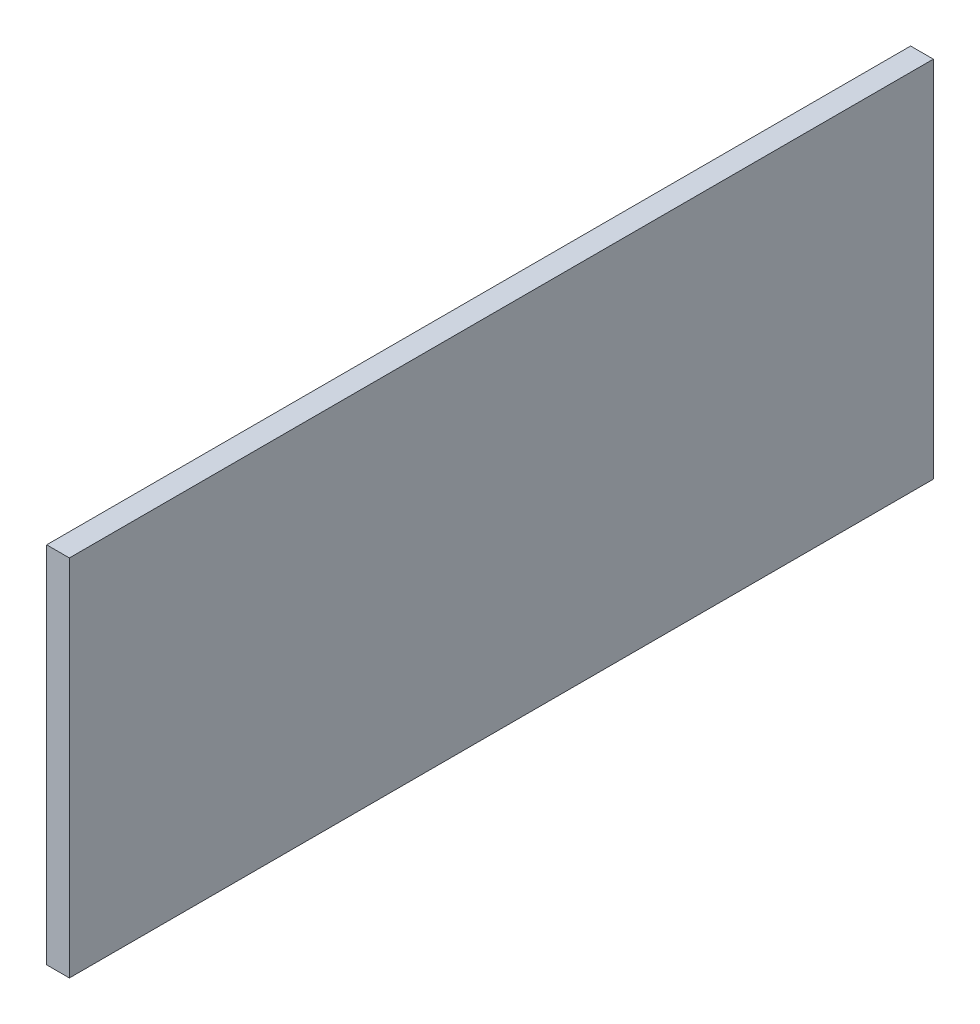
from build123d import *

# Parameters (mm, degrees)
SKETCH1_W           = 203.2
SKETCH1_H           = 120.65
BOSS_EXTRUDE1_DEPTH = 50.8
SKETCH2_W           = 196.85
SKETCH2_H           = 114.3
CUT_EXTRUDE1_DEPTH  = 51.8
SKETCH4_W           = 203.2
SKETCH4_H           = 120.65
SKETCH4_W_2         = 196.85
SKETCH4_H_2         = 114.3
BOSS_EXTRUDE2_DEPTH = 6.35
CUT_EXTRUDE5_DEPTH  = 121.65
CUT_EXTRUDE6_REACH  = 205.2
CUT_EXTRUDE7_REACH  = 205.2
SKETCH13_R          = 12.55395
SKETCH14_W          = 200.025
SKETCH14_H          = 120.65
CUT_EXTRUDE8_DEPTH  = 51.8
BOSS_EXTRUDE3_DEPTH = 3.175


with BuildPart() as part:
    # Sketch1 → Boss-Extrude1 (new body)
    with BuildSketch(Plane(origin=(0, 0, 0), x_dir=(1, 0, 0), z_dir=(0, 1, 0))):
        Rectangle(SKETCH1_W, SKETCH1_H)
    extrude(amount=BOSS_EXTRUDE1_DEPTH)

    # Sketch2 → Cut-Extrude1 (cut, through all)
    with BuildSketch(Plane(origin=(0, 50.8, 0), x_dir=(1, 0, 0), z_dir=(0, 1, 0))):
        Rectangle(SKETCH2_W, SKETCH2_H)
    extrude(amount=-CUT_EXTRUDE1_DEPTH, mode=Mode.SUBTRACT)

    # Sketch4 → Boss-Extrude2 (add)
    with BuildSketch(Plane(origin=(0, 50.8, 0), x_dir=(1, 0, 0), z_dir=(0, 1, 0))):
        Rectangle(SKETCH4_W, SKETCH4_H)
        Rectangle(SKETCH4_W_2, SKETCH4_H_2, mode=Mode.SUBTRACT)
    extrude(amount=-BOSS_EXTRUDE2_DEPTH)

    # Sketch10 → Cut-Extrude5 (cut, through all)
    with BuildSketch(Plane.XY.offset(60.325)):
        with BuildLine():
            ThreePointArc((-65.9511, 22.225), (-81.206975571, 31.167602912), (-81.556705839, 13.4874))
            Line((-81.556705839, 13.4874), (-70.843294161, 13.4874))
            ThreePointArc((-70.843294161, 13.4874), (-67.257397088, 17.218024429), (-65.9511, 22.225))
        make_face()
        with BuildLine():
            ThreePointArc((-15.1511, 22.225), (-30.406975571, 31.167602912), (-30.756705839, 13.4874))
            Line((-30.756705839, 13.4874), (-20.043294161, 13.4874))
            ThreePointArc((-20.043294161, 13.4874), (-16.457397088, 17.218024429), (-15.1511, 22.225))
        make_face()
        with BuildLine():
            ThreePointArc((35.6489, 22.225), (20.393024429, 31.167602912), (20.043294161, 13.4874))
            Line((20.043294161, 13.4874), (30.756705839, 13.4874))
            ThreePointArc((30.756705839, 13.4874), (34.342602912, 17.218024429), (35.6489, 22.225))
        make_face()
        with BuildLine():
            Line((70.843294161, 13.4874), (81.556705839, 13.4874))
            ThreePointArc((81.556705839, 13.4874), (85.142602912, 17.218024429), (86.4489, 22.225))
            ThreePointArc((86.4489, 22.225), (71.193024429, 31.167602912), (70.843294161, 13.4874))
        make_face()
    extrude(amount=-CUT_EXTRUDE5_DEPTH, mode=Mode.SUBTRACT)

    # Sketch12 → Cut-Extrude6 (cut, up to next)
    with BuildSketch(Plane(origin=(101.6, 0, 0), x_dir=(0, 0, -1), z_dir=(1, 0, 0)), mode=Mode.PRIVATE) as cut_extrude6_sk1:
        with BuildLine():
            ThreePointArc((-20.043294161, 19.8374), (-25.4, 38.8239), (-30.756705839, 19.8374))
            Line((-30.756705839, 19.8374), (-20.043294161, 19.8374))
        make_face()
    cut_extrude6_tool1 = extrude(cut_extrude6_sk1.sketch, amount=-CUT_EXTRUDE6_REACH, mode=Mode.PRIVATE) & part.part
    add(cut_extrude6_tool1.solids().sort_by_distance((101.6, 28.896198, 25.4))[0], mode=Mode.SUBTRACT)
    # Sketch12 → Cut-Extrude6 (cut, up to next)
    with BuildSketch(Plane(origin=(101.6, 0, 0), x_dir=(0, 0, -1), z_dir=(1, 0, 0)), mode=Mode.PRIVATE) as cut_extrude6_sk2:
        with BuildLine():
            ThreePointArc((30.756705839, 19.8374), (25.4, 38.8239), (20.043294161, 19.8374))
            Line((20.043294161, 19.8374), (30.756705839, 19.8374))
        make_face()
    cut_extrude6_tool2 = extrude(cut_extrude6_sk2.sketch, amount=-CUT_EXTRUDE6_REACH, mode=Mode.PRIVATE) & part.part
    add(cut_extrude6_tool2.solids().sort_by_distance((101.6, 28.896198, -25.4))[0], mode=Mode.SUBTRACT)

    # Sketch13 → Cut-Extrude7 (cut, up to next)
    with BuildSketch(Plane.ZY.offset(101.6), mode=Mode.PRIVATE) as cut_extrude7_sk1:
        with Locations((15.875, 28.575)):
            Circle(SKETCH13_R)
    cut_extrude7_tool1 = extrude(cut_extrude7_sk1.sketch, amount=-CUT_EXTRUDE7_REACH, mode=Mode.PRIVATE) & part.part
    add(cut_extrude7_tool1.solids().sort_by_distance((-101.6, 28.575, 15.875))[0], mode=Mode.SUBTRACT)

    # Sketch14 → Cut-Extrude8 (cut, through all)
    with BuildSketch(Plane(origin=(0, 50.8, 0), x_dir=(1, 0, 0), z_dir=(0, 1, 0))):
        with Locations((-1.5875, 0)):
            Rectangle(SKETCH14_W, SKETCH14_H)
    extrude(amount=-CUT_EXTRUDE8_DEPTH, mode=Mode.SUBTRACT)

    # Sketch15 → Boss-Extrude3 (add)
    with BuildSketch(Plane(origin=(101.6, 0, 0), x_dir=(0, 0, -1), z_dir=(1, 0, 0))):
        with BuildLine():
            Line((20.043294161, 19.8374), (30.756705839, 19.8374))
            ThreePointArc((30.756705839, 19.8374), (25.4, 38.8239), (20.043294161, 19.8374))
        make_face()
        with BuildLine():
            Line((-30.756705839, 19.8374), (-20.043294161, 19.8374))
            ThreePointArc((-20.043294161, 19.8374), (-25.4, 38.8239), (-30.756705839, 19.8374))
        make_face()
    extrude(amount=-BOSS_EXTRUDE3_DEPTH)


solid = part.part
